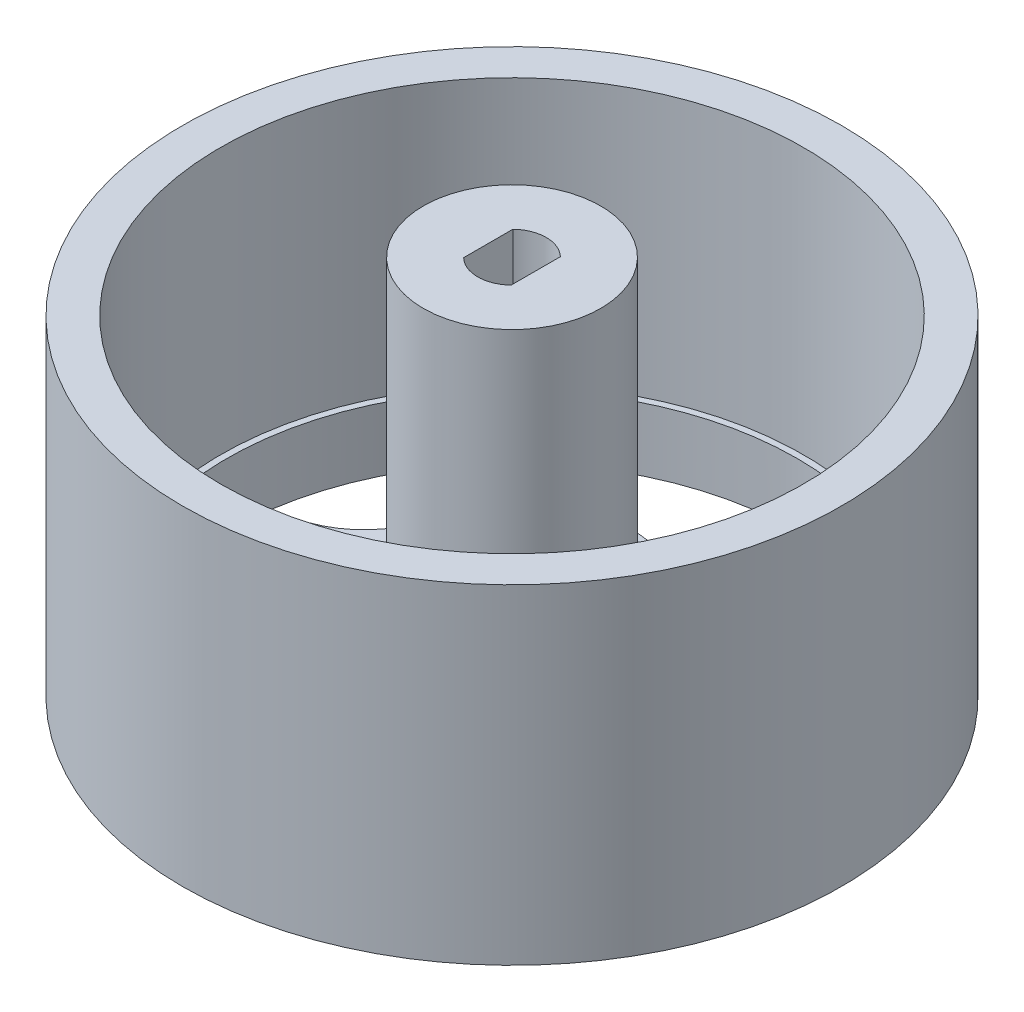
from build123d import *

# Parameters (mm, degrees)
SKETCH1_R           = 26
BOSS_EXTRUDE1_DEPTH = 26
SKETCH2_R           = 23
CUT_EXTRUDE1_DEPTH  = 21
CUT_EXTRUDE2_DEPTH  = 21
SKETCH6_R           = 7
BOSS_EXTRUDE2_DEPTH = 25
CUT_EXTRUDE3_DEPTH  = 8


with BuildPart() as part:
    # Sketch1 → Boss-Extrude1 (new body)
    with BuildSketch(Plane(origin=(0, 0, 0), x_dir=(1, 0, 0), z_dir=(0, 1, 0))):
        Circle(SKETCH1_R)
    extrude(amount=BOSS_EXTRUDE1_DEPTH)

    # Sketch2 → Cut-Extrude1 (cut)
    with BuildSketch(Plane(origin=(0, 26, 0), x_dir=(1, 0, 0), z_dir=(0, 1, 0))):
        Circle(SKETCH2_R)
    extrude(amount=-CUT_EXTRUDE1_DEPTH, mode=Mode.SUBTRACT)

    # Sketch3 → Cut-Extrude2 (cut)
    with BuildSketch(Plane.XZ):
        with BuildLine():
            Line((-3.257409457, 22.262957657), (-3.50001968, 14.501403797))
            ThreePointArc((-3.50001968, 14.501403797), (-6.465637776, 8.899186938), (-12.710089015, 7.809896739))
            Line((-12.710089015, 7.809896739), (-20.166736072, 9.977612751))
            ThreePointArc((-20.166736072, 9.977612751), (-13.225168177, 18.202882373), (-3.257409457, 22.262957657))
        make_face()
        with BuildLine():
            Line((20.166736072, 9.977612751), (12.710089014, 7.809896739))
            ThreePointArc((12.710089014, 7.809896739), (6.465637775, 8.899186939), (3.50001968, 14.501403797))
            Line((3.50001968, 14.501403797), (3.257409457, 22.262957657))
            ThreePointArc((3.257409457, 22.262957657), (13.225168177, 18.202882373), (20.166736072, 9.977612751))
        make_face()
        with BuildLine():
            Line((15.721137791, -16.09645385), (11.355286691, -9.674622163))
            ThreePointArc((11.355286691, -9.674622163), (10.46162168, -3.399186938), (14.873220138, 1.152463692))
            Line((14.873220138, 1.152463692), (22.179925831, 3.781651771))
            ThreePointArc((22.179925831, 3.781651771), (21.398771617, -6.952882373), (15.721137791, -16.09645385))
        make_face()
        with BuildLine():
            Line((-10.450538575, -19.925768329), (-5.692135888, -13.789142064))
            ThreePointArc((-5.692135888, -13.789142064), (0, -11), (5.692135888, -13.789142064))
            Line((5.692135888, -13.789142064), (10.450538575, -19.925768329))
            ThreePointArc((10.450538575, -19.925768329), (0, -22.5), (-10.450538575, -19.925768329))
        make_face()
        with BuildLine():
            Line((-22.179925831, 3.781651771), (-14.873220138, 1.152463692))
            ThreePointArc((-14.873220138, 1.152463692), (-10.46162168, -3.399186938), (-11.355286691, -9.674622163))
            Line((-11.355286691, -9.674622163), (-15.721137791, -16.09645385))
            ThreePointArc((-15.721137791, -16.09645385), (-21.398771617, -6.952882373), (-22.179925831, 3.781651771))
        make_face()
    extrude(amount=-CUT_EXTRUDE2_DEPTH, mode=Mode.SUBTRACT)

    # Sketch5 → Cut-Revolve1 (revolve, cut)
    with BuildSketch(Plane.XY):
        with BuildLine():
            Line((18.5, 0), (22.5, 0))
            Line((22.5, 0), (22.5, 4))
            ThreePointArc((22.5, 4), (21.328427125, 1.171572875), (18.5, 0))
        make_face()
        Polygon((0, 0), (0, 2.5), (5, 2.5), (5, 4), (7.5, 4), (9, 0), align=None)
    revolve(axis=Axis((0, 26, 0), (0, -1, 0)), mode=Mode.SUBTRACT)

    # Sketch6 → Boss-Extrude2 (add)
    with BuildSketch(Plane(origin=(0, 5, 0), x_dir=(1, 0, 0), z_dir=(0, 1, 0))):
        Circle(SKETCH6_R)
    extrude(amount=BOSS_EXTRUDE2_DEPTH)

    # Sketch7 → Cut-Extrude3 (cut)
    with BuildSketch(Plane(origin=(0, 30, 0), x_dir=(1, 0, 0), z_dir=(0, 1, 0))):
        with BuildLine():
            Line((-1.875, 0), (-1.875, 1.942775077))
            ThreePointArc((-1.875, 1.942775077), (0, 2.7), (1.875, 1.942775077))
            Line((1.875, 1.942775077), (1.875, 0))
            Line((1.875, 0), (1.875, -1.942775077))
            ThreePointArc((1.875, -1.942775077), (0, -2.7), (-1.875, -1.942775077))
            Line((-1.875, -1.942775077), (-1.875, 0))
        make_face()
    extrude(amount=-CUT_EXTRUDE3_DEPTH, mode=Mode.SUBTRACT)


solid = part.part
